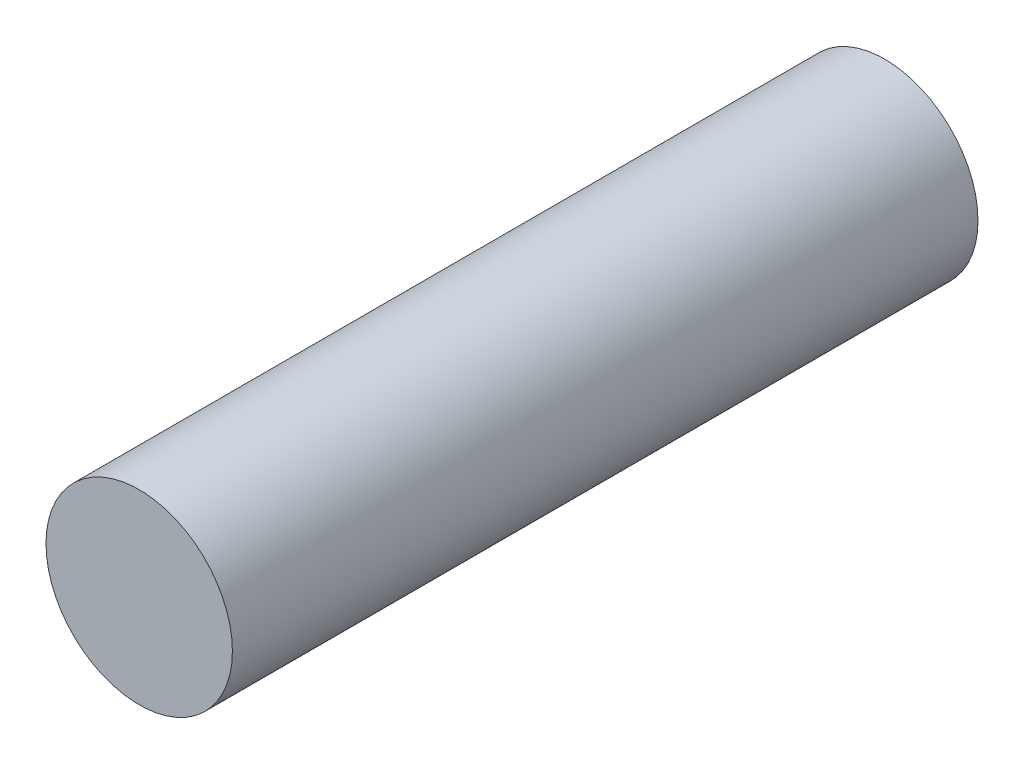
from build123d import *

# Parameters (mm, degrees)
SKETCH_1_R      = 1.5
EXTRUDE_1_DEPTH = 12


with BuildPart() as part:
    # 草图1 → 凸台-拉伸1 (new body)
    with BuildSketch(Plane.XY):
        Circle(SKETCH_1_R)
    extrude(amount=EXTRUDE_1_DEPTH)


solid = part.part
